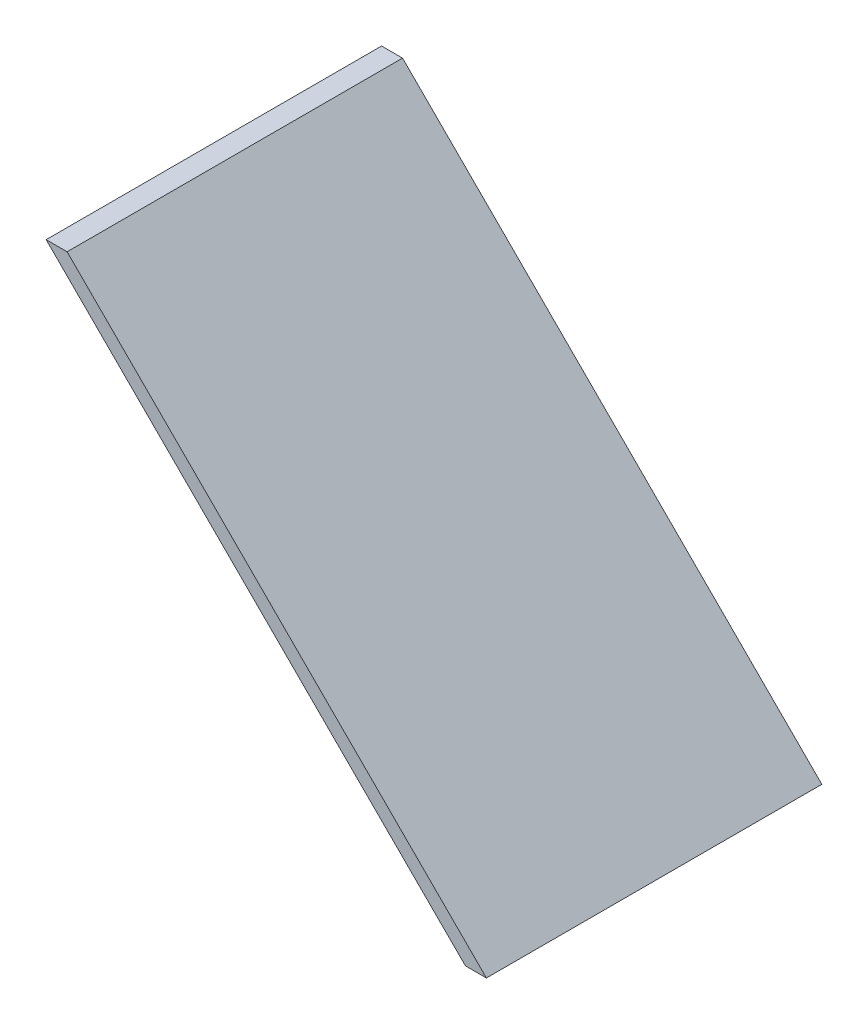
from build123d import *

# Parameters (mm, degrees)
BOSS_EXTRUDE1_DEPTH = 80


with BuildPart() as part:
    # Sketch1 → Boss-Extrude1 (new body)
    with BuildSketch(Plane.XY):
        Polygon((0, 100), (100, 0), (105, 0), (5, 100), align=None)
    extrude(amount=BOSS_EXTRUDE1_DEPTH)


solid = part.part
